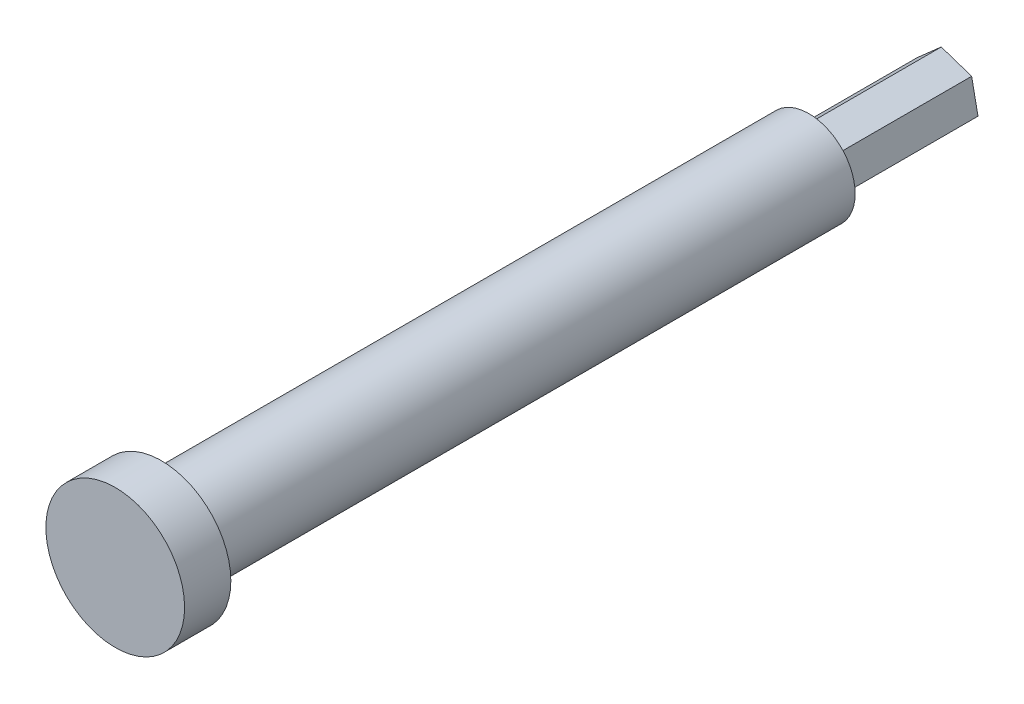
from build123d import *

# Parameters (mm, degrees)
BOSS_EXTRU_1_DEPTH = 15
ESQUISSE2_R        = 5
BOSS_EXTRU_2_DEPTH = 70
ESQUISSE3_R        = 7.5
BOSS_EXTRU_3_DEPTH = 5


with BuildPart() as part:
    # Esquisse1 → Boss.-Extru.1 (new body)
    with BuildSketch(Plane.XY):
        Polygon((-0.686649648, 3.395366293), (-3.283798289, 1.103027108), (-2.597148641, -2.292339185), (0.686649648, -3.395366293), (3.283798289, -1.103027108), (2.597148641, 2.292339185), align=None)
    extrude(amount=BOSS_EXTRU_1_DEPTH)

    # Esquisse2 → Boss.-Extru.2 (add)
    with BuildSketch(Plane.XY.offset(15)):
        Circle(ESQUISSE2_R)
    extrude(amount=BOSS_EXTRU_2_DEPTH)

    # Esquisse3 → Boss.-Extru.3 (add)
    with BuildSketch(Plane.XY.offset(85)):
        Circle(ESQUISSE3_R)
    extrude(amount=BOSS_EXTRU_3_DEPTH)


solid = part.part
